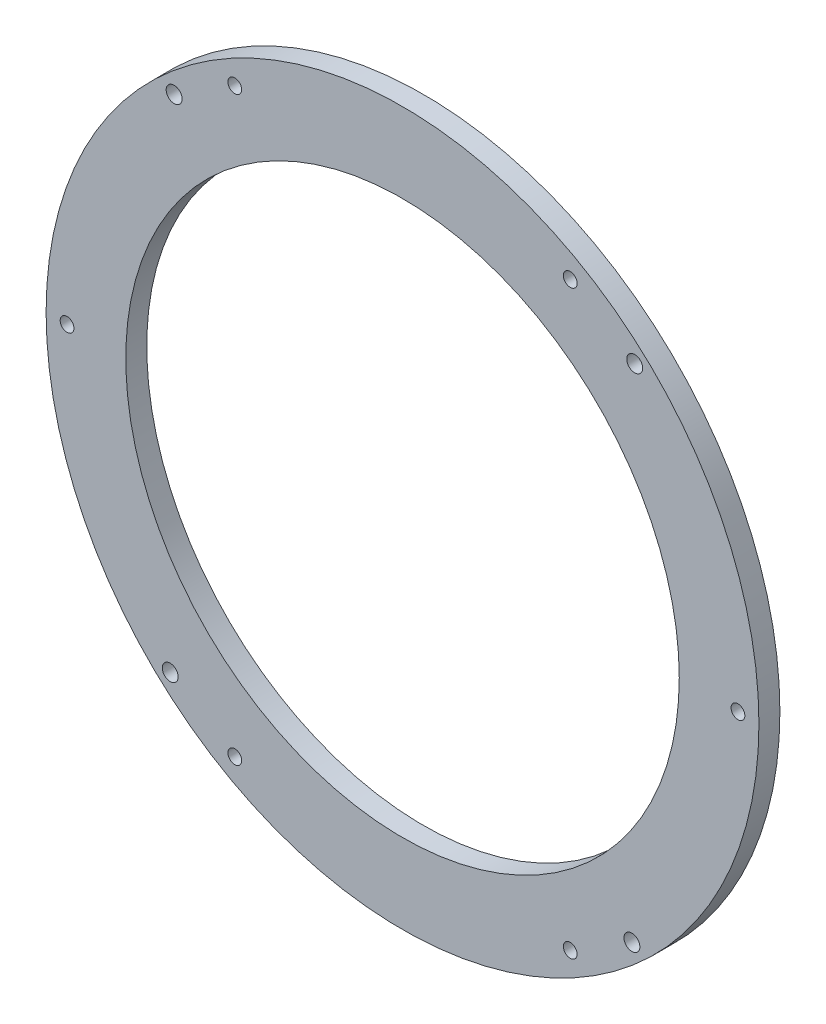
from build123d import *

# Parameters (mm, degrees)
SKETCH1_R           = 107.95
SKETCH1_R_2         = 83.82
BOSS_EXTRUDE1_DEPTH = 6.35
SKETCH2_R           = 2.085
SKETCH2_R_2         = 2.413
CUT_EXTRUDE1_DEPTH  = 21.336
SKETCH5_R           = 2.413
CUT_EXTRUDE4_DEPTH  = 6.35


with BuildPart() as part:
    # Sketch1 → Boss-Extrude1 (new body)
    with BuildSketch(Plane.XY):
        with Locations((51.738381467, 55.593319394)):
            Circle(SKETCH1_R)
        with Locations((51.738381467, 55.593319394)):
            Circle(SKETCH1_R_2, mode=Mode.SUBTRACT)
    extrude(amount=BOSS_EXTRUDE1_DEPTH)

    # Sketch2 → Cut-Extrude1 (cut)
    with BuildSketch(Plane(origin=(0, 0, 0), x_dir=(-1, 0, 0), z_dir=(0, 0, -1))):
        with Locations((-0.938381467, -32.39486163)):
            Circle(SKETCH2_R)
        with Locations((-102.538381467, -32.39486163)):
            Circle(SKETCH2_R)
        with Locations((-153.338381467, 55.593319394)):
            Circle(SKETCH2_R)
        with Locations((-102.538381467, 143.581500419)):
            Circle(SKETCH2_R)
        with Locations((-0.938381467, 143.581500419)):
            Circle(SKETCH2_R)
        with Locations((49.861618533, 55.593319394)):
            Circle(SKETCH2_R)
        with Locations((-121.212212689, -20.941506669)):
            Circle(SKETCH2_R_2)
        with Locations((18.615381385, -20.066128285)):
            Circle(SKETCH2_R_2)
    extrude(amount=-CUT_EXTRUDE1_DEPTH, mode=Mode.SUBTRACT)

    # Sketch5 → Cut-Extrude4 (cut)
    with BuildSketch(Plane.XY.offset(6.35)):
        with Locations((122.06341072, 131.252946958)):
            Circle(SKETCH5_R)
        with Locations((-17.430655728, 132.126237322)):
            Circle(SKETCH5_R)
    extrude(amount=-CUT_EXTRUDE4_DEPTH, mode=Mode.SUBTRACT)


solid = part.part
